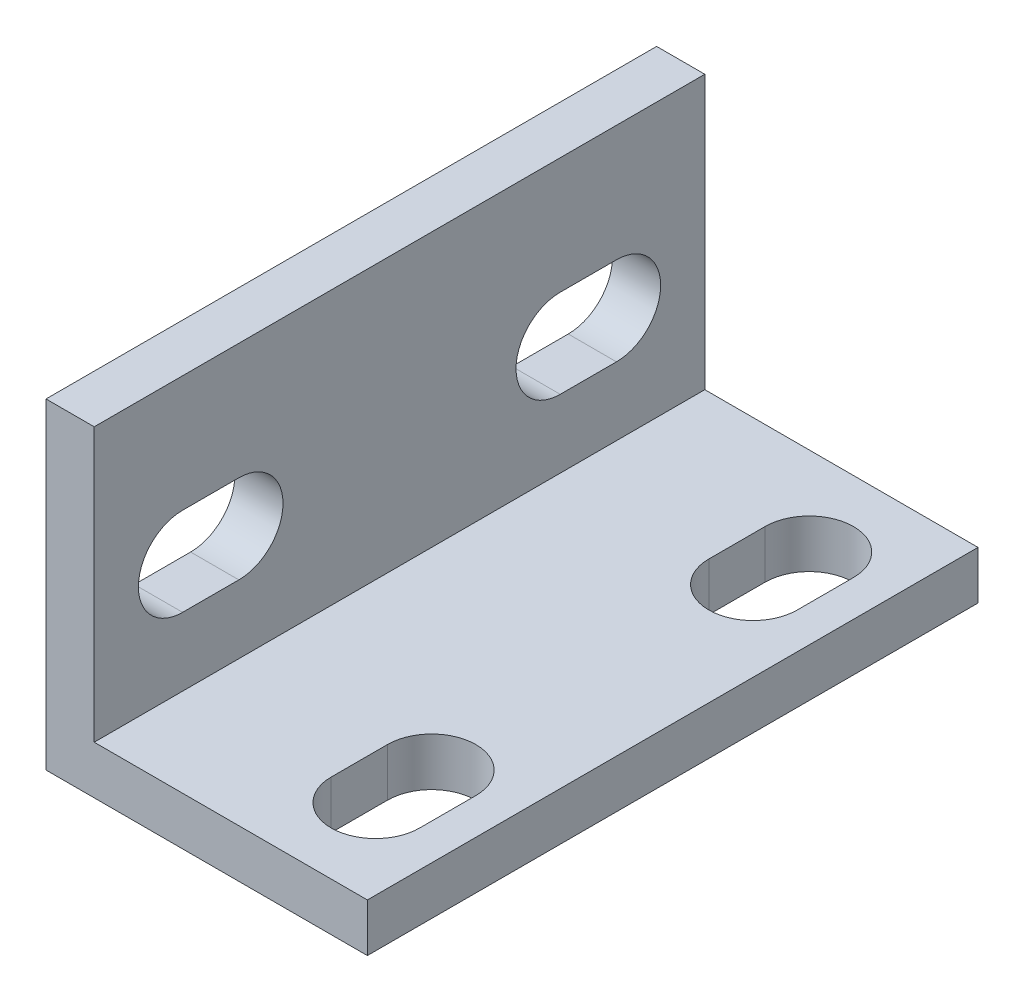
from build123d import *

# Parameters (mm, degrees)
EXTRUDE_THIN1_DEPTH = 38
CUT_EXTRUDE1_DEPTH  = 4
CUT_EXTRUDE2_DEPTH  = 4


with BuildPart() as part:
    # Sketch1 → Extrude-Thin1 (new body)
    with BuildSketch(Plane.XY):
        Polygon((0, 20), (0, 0), (20, 0), (20, 3), (3, 3), (3, 20), align=None)
    extrude(amount=EXTRUDE_THIN1_DEPTH)

    # Sketch2 → Cut-Extrude1 (cut, through all)
    with BuildSketch(Plane(origin=(3, 0, 0), x_dir=(0, 0, -1), z_dir=(1, 0, 0))):
        with BuildLine():
            Line((-29, 7.25), (-32.5, 7.25))
            ThreePointArc((-32.5, 7.25), (-35.25, 10), (-32.5, 12.75))
            Line((-32.5, 12.75), (-29, 12.75))
            ThreePointArc((-29, 12.75), (-26.25, 10), (-29, 7.25))
        make_face()
        with BuildLine():
            Line((-9, 7.25), (-5.5, 7.25))
            ThreePointArc((-5.5, 7.25), (-2.75, 10), (-5.5, 12.75))
            Line((-5.5, 12.75), (-9, 12.75))
            ThreePointArc((-9, 12.75), (-11.75, 10), (-9, 7.25))
        make_face()
    extrude(amount=-CUT_EXTRUDE1_DEPTH, mode=Mode.SUBTRACT)

    # Sketch3 → Cut-Extrude2 (cut, through all)
    with BuildSketch(Plane(origin=(0, 3, 0), x_dir=(1, 0, 0), z_dir=(0, 1, 0))):
        with BuildLine():
            Line((12.25, -32.5), (12.25, -29))
            ThreePointArc((12.25, -29), (15, -26.25), (17.75, -29))
            Line((17.75, -29), (17.75, -32.5))
            ThreePointArc((17.75, -32.5), (15, -35.25), (12.25, -32.5))
        make_face()
        with BuildLine():
            Line((12.25, -5.5), (12.25, -9))
            ThreePointArc((12.25, -9), (15, -11.75), (17.75, -9))
            Line((17.75, -9), (17.75, -5.5))
            ThreePointArc((17.75, -5.5), (15, -2.75), (12.25, -5.5))
        make_face()
    extrude(amount=-CUT_EXTRUDE2_DEPTH, mode=Mode.SUBTRACT)


solid = part.part
